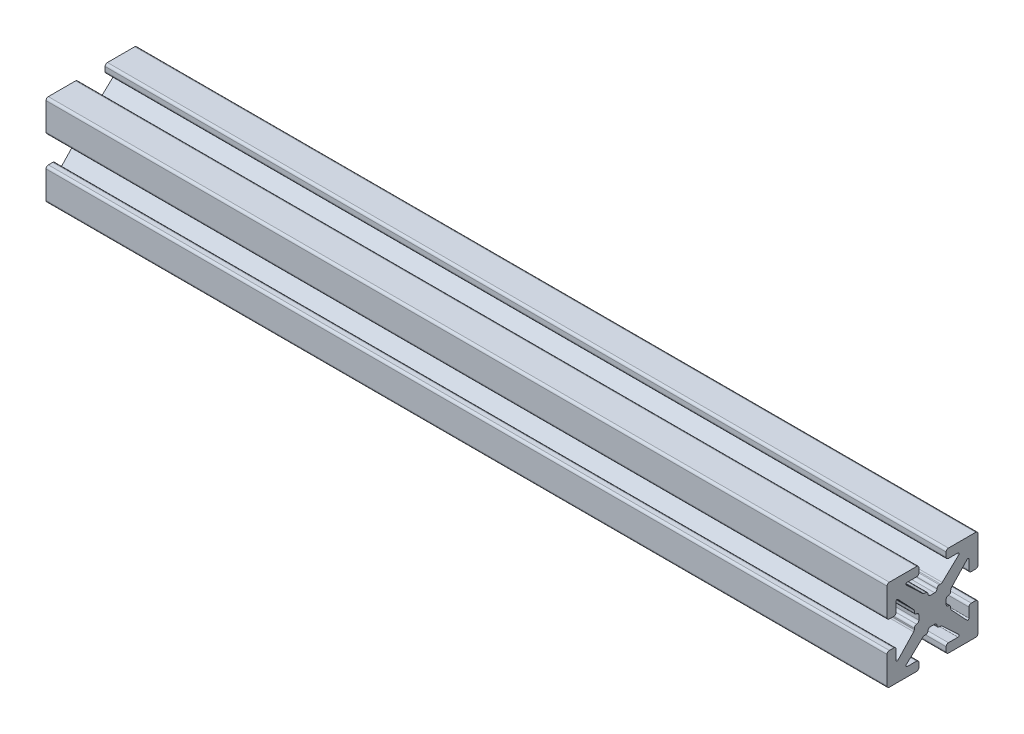
from build123d import *

# Parameters (mm, degrees)
BOSS_EXTRU_1_DEPTH = 92.5


with BuildPart() as part:
    # Sketch1 → Boss.-Extru.1 (new body)
    with BuildSketch(Plane(origin=(0, 0, 0), x_dir=(0, 0, -1), z_dir=(1, 0, 0))):
        with BuildLine():
            Line((-0.2413, 1.4986), (0.2413, 1.4986))
            ThreePointArc((0.2413, 1.4986), (0.420905122, 1.572994878), (0.4953, 1.7526))
            ThreePointArc((0.4953, 1.7526), (0.569694878, 1.932205122), (0.7493, 2.0066))
            Line((0.7493, 2.0066), (0.889923986, 2.0066))
            ThreePointArc((0.889923986, 2.0066), (0.983516259, 2.024471886), (1.063937899, 2.075572548))
            Line((1.063937899, 2.075572548), (2.890793, 3.793686274))
            ThreePointArc((2.890793, 3.793686274), (2.921850101, 3.932996137), (2.803786044, 4.0132))
            Line((2.803786044, 4.0132), (1.7526, 4.0132))
            ThreePointArc((1.7526, 4.0132), (1.572994878, 4.087594878), (1.4986, 4.2672))
            Line((1.4986, 4.2672), (1.4986, 4.7498))
            ThreePointArc((1.4986, 4.7498), (1.572994878, 4.929405122), (1.7526, 5.0038))
            Line((1.7526, 5.0038), (4.7498, 5.0038))
            ThreePointArc((4.7498, 5.0038), (4.929405122, 4.929405122), (5.0038, 4.7498))
            Line((5.0038, 4.7498), (5.0038, 1.7526))
            ThreePointArc((5.0038, 1.7526), (4.929405122, 1.572994878), (4.7498, 1.4986))
            Line((4.7498, 1.4986), (4.2672, 1.4986))
            ThreePointArc((4.2672, 1.4986), (4.087594878, 1.572994878), (4.0132, 1.7526))
            Line((4.0132, 1.7526), (4.0132, 2.803786044))
            ThreePointArc((4.0132, 2.803786044), (3.932996137, 2.921850101), (3.793686274, 2.890793))
            Line((3.793686274, 2.890793), (2.075572548, 1.063937899))
            ThreePointArc((2.075572548, 1.063937899), (2.024471886, 0.983516259), (2.0066, 0.889923986))
            Line((2.0066, 0.889923986), (2.0066, 0.7493))
            ThreePointArc((2.0066, 0.7493), (1.932205122, 0.569694878), (1.7526, 0.4953))
            ThreePointArc((1.7526, 0.4953), (1.572994878, 0.420905122), (1.4986, 0.2413))
            Line((1.4986, 0.2413), (1.4986, -0.2413))
            ThreePointArc((1.4986, -0.2413), (1.572994878, -0.420905122), (1.7526, -0.4953))
            ThreePointArc((1.7526, -0.4953), (1.932205122, -0.569694878), (2.0066, -0.7493))
            Line((2.0066, -0.7493), (2.0066, -0.889923986))
            ThreePointArc((2.0066, -0.889923986), (2.024471886, -0.983516259), (2.075572548, -1.063937899))
            Line((2.075572548, -1.063937899), (3.793686274, -2.890793))
            ThreePointArc((3.793686274, -2.890793), (3.932996137, -2.921850101), (4.0132, -2.803786044))
            Line((4.0132, -2.803786044), (4.0132, -1.7526))
            ThreePointArc((4.0132, -1.7526), (4.087594878, -1.572994878), (4.2672, -1.4986))
            Line((4.2672, -1.4986), (4.7498, -1.4986))
            ThreePointArc((4.7498, -1.4986), (4.929405122, -1.572994878), (5.0038, -1.7526))
            Line((5.0038, -1.7526), (5.0038, -4.7498))
            ThreePointArc((5.0038, -4.7498), (4.929405122, -4.929405122), (4.7498, -5.0038))
            Line((4.7498, -5.0038), (1.7526, -5.0038))
            ThreePointArc((1.7526, -5.0038), (1.572994878, -4.929405122), (1.4986, -4.7498))
            Line((1.4986, -4.7498), (1.4986, -4.2672))
            ThreePointArc((1.4986, -4.2672), (1.572994878, -4.087594878), (1.7526, -4.0132))
            Line((1.7526, -4.0132), (2.803786044, -4.0132))
            ThreePointArc((2.803786044, -4.0132), (2.921850101, -3.932996137), (2.890793, -3.793686274))
            Line((2.890793, -3.793686274), (1.063937899, -2.075572548))
            ThreePointArc((1.063937899, -2.075572548), (0.983516259, -2.024471886), (0.889923986, -2.0066))
            Line((0.889923986, -2.0066), (0.7493, -2.0066))
            ThreePointArc((0.7493, -2.0066), (0.569694878, -1.932205122), (0.4953, -1.7526))
            ThreePointArc((0.4953, -1.7526), (0.420905122, -1.572994878), (0.2413, -1.4986))
            Line((0.2413, -1.4986), (-0.2413, -1.4986))
            ThreePointArc((-0.2413, -1.4986), (-0.420905122, -1.572994878), (-0.4953, -1.7526))
            ThreePointArc((-0.4953, -1.7526), (-0.569694878, -1.932205122), (-0.7493, -2.0066))
            Line((-0.7493, -2.0066), (-0.889923986, -2.0066))
            ThreePointArc((-0.889923986, -2.0066), (-0.983516259, -2.024471886), (-1.063937899, -2.075572548))
            Line((-1.063937899, -2.075572548), (-2.890793, -3.793686274))
            ThreePointArc((-2.890793, -3.793686274), (-2.921850101, -3.932996137), (-2.803786044, -4.0132))
            Line((-2.803786044, -4.0132), (-1.7526, -4.0132))
            ThreePointArc((-1.7526, -4.0132), (-1.572994878, -4.087594878), (-1.4986, -4.2672))
            Line((-1.4986, -4.2672), (-1.4986, -4.7498))
            ThreePointArc((-1.4986, -4.7498), (-1.572994878, -4.929405122), (-1.7526, -5.0038))
            Line((-1.7526, -5.0038), (-4.7498, -5.0038))
            ThreePointArc((-4.7498, -5.0038), (-4.929405122, -4.929405122), (-5.0038, -4.7498))
            Line((-5.0038, -4.7498), (-5.0038, -1.7526))
            ThreePointArc((-5.0038, -1.7526), (-4.929405122, -1.572994878), (-4.7498, -1.4986))
            Line((-4.7498, -1.4986), (-4.2672, -1.4986))
            ThreePointArc((-4.2672, -1.4986), (-4.087594878, -1.572994878), (-4.0132, -1.7526))
            Line((-4.0132, -1.7526), (-4.0132, -2.803786044))
            ThreePointArc((-4.0132, -2.803786044), (-3.932996137, -2.921850101), (-3.793686274, -2.890793))
            Line((-3.793686274, -2.890793), (-2.075572548, -1.063937899))
            ThreePointArc((-2.075572548, -1.063937899), (-2.024471886, -0.983516259), (-2.0066, -0.889923986))
            Line((-2.0066, -0.889923986), (-2.0066, -0.7493))
            ThreePointArc((-2.0066, -0.7493), (-1.932205122, -0.569694878), (-1.7526, -0.4953))
            ThreePointArc((-1.7526, -0.4953), (-1.572994878, -0.420905122), (-1.4986, -0.2413))
            Line((-1.4986, -0.2413), (-1.4986, 0.2413))
            ThreePointArc((-1.4986, 0.2413), (-1.572994878, 0.420905122), (-1.7526, 0.4953))
            ThreePointArc((-1.7526, 0.4953), (-1.932205122, 0.569694878), (-2.0066, 0.7493))
            Line((-2.0066, 0.7493), (-2.0066, 0.889923986))
            ThreePointArc((-2.0066, 0.889923986), (-2.024471886, 0.983516259), (-2.075572548, 1.063937899))
            Line((-2.075572548, 1.063937899), (-3.793686274, 2.890793))
            ThreePointArc((-3.793686274, 2.890793), (-3.932996137, 2.921850101), (-4.0132, 2.803786044))
            Line((-4.0132, 2.803786044), (-4.0132, 1.7526))
            ThreePointArc((-4.0132, 1.7526), (-4.087594878, 1.572994878), (-4.2672, 1.4986))
            Line((-4.2672, 1.4986), (-4.7498, 1.4986))
            ThreePointArc((-4.7498, 1.4986), (-4.929405122, 1.572994878), (-5.0038, 1.7526))
            Line((-5.0038, 1.7526), (-5.0038, 4.7498))
            ThreePointArc((-5.0038, 4.7498), (-4.929405122, 4.929405122), (-4.7498, 5.0038))
            Line((-4.7498, 5.0038), (-1.7526, 5.0038))
            ThreePointArc((-1.7526, 5.0038), (-1.572994878, 4.929405122), (-1.4986, 4.7498))
            Line((-1.4986, 4.7498), (-1.4986, 4.2672))
            ThreePointArc((-1.4986, 4.2672), (-1.572994878, 4.087594878), (-1.7526, 4.0132))
            Line((-1.7526, 4.0132), (-2.803786044, 4.0132))
            ThreePointArc((-2.803786044, 4.0132), (-2.921850101, 3.932996137), (-2.890793, 3.793686274))
            Line((-2.890793, 3.793686274), (-1.063937899, 2.075572548))
            ThreePointArc((-1.063937899, 2.075572548), (-0.983516259, 2.024471886), (-0.889923986, 2.0066))
            Line((-0.889923986, 2.0066), (-0.7493, 2.0066))
            ThreePointArc((-0.7493, 2.0066), (-0.569694878, 1.932205122), (-0.4953, 1.7526))
            ThreePointArc((-0.4953, 1.7526), (-0.420905122, 1.572994878), (-0.2413, 1.4986))
        make_face()
    extrude(amount=BOSS_EXTRU_1_DEPTH)


solid = part.part
